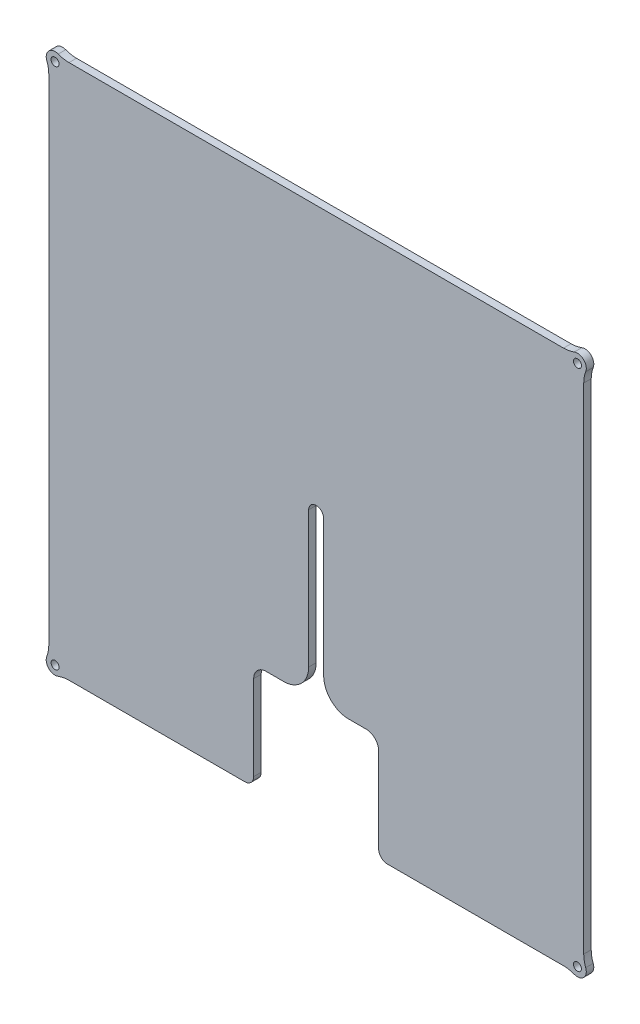
from build123d import *

# Parameters (mm, degrees)
SKETCH1_R           = 1.6
BOSS_EXTRUDE1_DEPTH = 3
CUT_EXTRUDE5_DEPTH  = 4
FILLET1_R           = 3.54


with BuildPart() as part:
    # Sketch1 → Boss-Extrude1 (new body)
    with BuildSketch(Plane.XY):
        with BuildLine():
            Line((-107, 98.923010333), (-107, -98.923010333))
            ThreePointArc((-107, -98.923010333), (-107.201661971, -101.11372249), (-107.799869959, -103.230804092))
            ThreePointArc((-107.799869959, -103.230804092), (-107, -107), (-103.230804092, -107.799869959))
            ThreePointArc((-103.230804092, -107.799869959), (-101.11372249, -107.201661971), (-98.923010333, -107))
            Line((-98.923010333, -107), (-43, -107))
            Line((-43, -107), (43, -107))
            Line((43, -107), (98.923010333, -107))
            ThreePointArc((98.923010333, -107), (101.11372249, -107.201661971), (103.230804092, -107.799869959))
            ThreePointArc((103.230804092, -107.799869959), (107, -107), (107.799869959, -103.230804092))
            ThreePointArc((107.799869959, -103.230804092), (107.201661971, -101.11372249), (107, -98.923010333))
            Line((107, -98.923010333), (107, 98.923010333))
            ThreePointArc((107, 98.923010333), (107.201661971, 101.11372249), (107.799869959, 103.230804092))
            ThreePointArc((107.799869959, 103.230804092), (107, 107), (103.230804092, 107.799869959))
            ThreePointArc((103.230804092, 107.799869959), (101.11372249, 107.201661971), (98.923010333, 107))
            Line((98.923010333, 107), (-98.923010333, 107))
            ThreePointArc((-98.923010333, 107), (-101.11372249, 107.201661971), (-103.230804092, 107.799869959))
            ThreePointArc((-103.230804092, 107.799869959), (-107, 107), (-107.799869959, 103.230804092))
            ThreePointArc((-107.799869959, 103.230804092), (-107.201661971, 101.11372249), (-107, 98.923010333))
        make_face()
        with Locations((-104.5, -104.5)):
            Circle(SKETCH1_R, mode=Mode.SUBTRACT)
        with Locations((-104.5, 104.5)):
            Circle(SKETCH1_R, mode=Mode.SUBTRACT)
        with Locations((104.5, 104.5)):
            Circle(SKETCH1_R, mode=Mode.SUBTRACT)
        with Locations((104.5, -104.5)):
            Circle(SKETCH1_R, mode=Mode.SUBTRACT)
    extrude(amount=BOSS_EXTRUDE1_DEPTH)

    # Sketch5 → Cut-Extrude5 (cut, through all)
    with BuildSketch(Plane.XY):
        with BuildLine():
            Line((-25.033358746, -107), (24.966641254, -107))
            Line((24.966641254, -107), (24.966641254, -69.5))
            ThreePointArc((24.966641254, -69.5), (23.50217516, -65.964466094), (19.966641254, -64.5))
            Line((19.966641254, -64.5), (12.966641254, -64.5))
            ThreePointArc((12.966641254, -64.5), (5.895573442, -61.571067812), (2.966641254, -54.5))
            Line((2.966641254, -54.5), (2.966641254, 0))
            ThreePointArc((2.966641254, 0), (-0.033358746, 3), (-3.033358746, 0))
            Line((-3.033358746, 0), (-3.033358746, -54.5))
            ThreePointArc((-3.033358746, -54.5), (-5.962290934, -61.571067812), (-13.033358746, -64.5))
            Line((-13.033358746, -64.5), (-20.033358746, -64.5))
            ThreePointArc((-20.033358746, -64.5), (-23.568892652, -65.964466094), (-25.033358746, -69.5))
            Line((-25.033358746, -69.5), (-25.033358746, -107))
        make_face()
    extrude(amount=CUT_EXTRUDE5_DEPTH, mode=Mode.SUBTRACT)

    # Fillet1
    fillet1_edges = [part.edges().sort_by_distance(p)[0] for p in [
        (-25.033358746, -107, 1.5),
        (24.966641254, -107, 1.5),
    ]]
    fillet(fillet1_edges, radius=FILLET1_R)


solid = part.part
